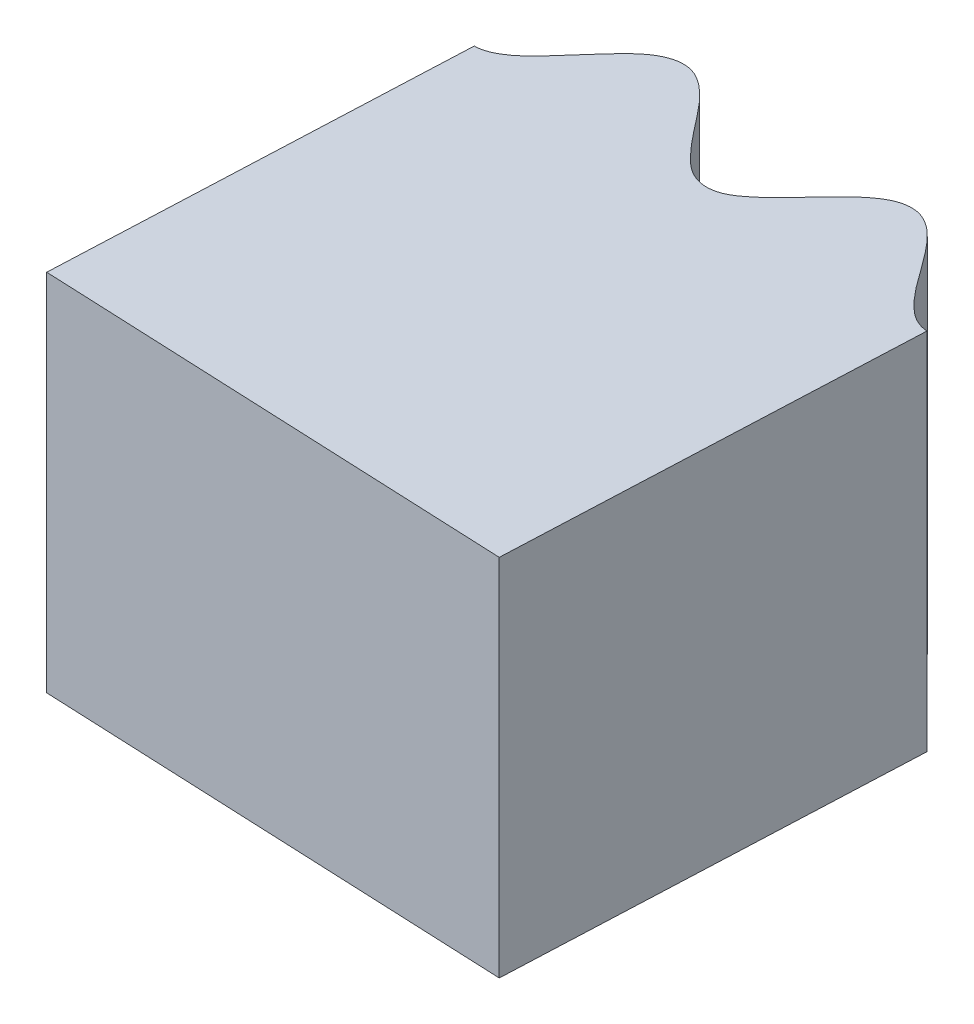
from build123d import *

# Parameters (mm, degrees)
BOSS_EXTRUDE1_DEPTH     = 4
CUT_EXTRUDE1_DEPTH      = 107.826952485
CUT_EXTRUDE1_DEPTH_BACK = 107.826952485
CUT_EXTRUDE2_DEPTH      = 107.826952485
CUT_EXTRUDE2_DEPTH_BACK = 107.826952485
BOSS_EXTRUDE2_DEPTH     = 4


with BuildPart() as part:
    # Sketch1 → Boss-Extrude1 (new body)
    with BuildSketch(Plane(origin=(0, 0, 0), x_dir=(1, 0, 0), z_dir=(0, 1, 0))):
        with BuildLine():
            Line((0, 75), (0, 70))
            ThreePointArc((0, 70), (49.497474683, 49.497474683), (70, 0))
            Line((70, 0), (75, 0))
            add(Edge.make_bspline(
                [(75, 0), (75.031777855, 0.026481546), (75.095718036, 0.079819595), (75.241427751, 0.203111666), (75.354120049, 0.325005398), (75.49263484, 0.505895966), (75.521616194, 0.741052344), (75.387194033, 0.961837859), (75.204794388, 1.132550458), (75.012763118, 1.292322408), (74.827909129, 1.434094195), (74.659688399, 1.589431482), (74.516508731, 1.747740796), (74.435301549, 1.990442591), (74.557176398, 2.236119215), (74.743732486, 2.433020792), (74.971286904, 2.627170766), (75.184213901, 2.831860151), (75.396738703, 3.044470229), (75.480370233, 3.37207249), (75.263556366, 3.636944802), (75.040650584, 3.822472036), (74.777383796, 4.010107495), (74.562819356, 4.184559741), (74.374958391, 4.384835516), (74.336857576, 4.635729115), (74.442274354, 4.835162175), (74.587135112, 5.0087381), (74.759757076, 5.179617259), (74.951973417, 5.354990353), (75.129486645, 5.551339985), (75.290054051, 5.777106095), (75.271282724, 6.055358963), (75.09620029, 6.247386328), (74.916555915, 6.398761228), (74.722111148, 6.530990099), (74.543350518, 6.654439025), (74.373583197, 6.786650419), (74.232516382, 6.923964863), (74.117997639, 7.140987023), (74.196142559, 7.40620448), (74.378877991, 7.621272004), (74.5932695, 7.846450763), (74.790579804, 8.043756236), (74.942235911, 8.240257531), (75.031626892, 8.443006893), (75.013933032, 8.637322476), (74.887419593, 8.818119346), (74.697982548, 8.975126902), (74.466865412, 9.123338974), (74.20856507, 9.289237483), (73.989820953, 9.451847774), (73.840027413, 9.667045575), (73.863757101, 9.895288267), (73.953590648, 10.058794794), (74.07609209, 10.222725068), (74.222147367, 10.387467054), (74.387036369, 10.561793098), (74.545599639, 10.760070197), (74.679775488, 10.9703129), (74.690515378, 11.221092601), (74.549634297, 11.408193312), (74.38809788, 11.539271657), (74.16550239, 11.683318077), (73.936586266, 11.812168652), (73.714963784, 11.954511577), (73.517288694, 12.139168151), (73.441094189, 12.359959327), (73.522095707, 12.580242239), (73.645005322, 12.764599436), (73.789630676, 12.941231814), (73.935098708, 13.109956075), (74.07848904, 13.287933998), (74.198419381, 13.473845208), (74.277410601, 13.707052688), (74.179200659, 13.944365708), (73.984265056, 14.097558217), (73.773817376, 14.231040782), (73.564520841, 14.340626908), (73.373575895, 14.447954179), (73.203525778, 14.562983122), (73.062426387, 14.689045185), (72.964311873, 14.898094952), (73.03521508, 15.149689821), (73.187174005, 15.373007802), (73.374719276, 15.611401558), (73.54101317, 15.820587549), (73.666083057, 16.021895989), (73.731374958, 16.217051043), (73.713914908, 16.39368128), (73.590497424, 16.570393243), (73.385208789, 16.714186298), (73.1668676, 16.827983407), (72.946766548, 16.93585278), (72.767754543, 17.03375874), (72.631281692, 17.124483788), (72.49758224, 17.242341241), (72.407119177, 17.423545501), (72.446790026, 17.638061133), (72.550050598, 17.829570173), (72.677037293, 18.016867634), (72.811599962, 18.196517221), (72.94890752, 18.387627652), (73.063188286, 18.586138857), (73.144605423, 18.830963502), (73.036496161, 19.080658625), (72.815265215, 19.226832107), (72.584482807, 19.351740928), (72.358507194, 19.448369637), (72.16218642, 19.544292981), (71.991493102, 19.64606248), (71.857216036, 19.756965783), (71.747380664, 19.953004782), (71.801427219, 20.215724769), (71.948636358, 20.460050217), (72.135214019, 20.731193805), (72.293878791, 20.968686197), (72.401411299, 21.196546331), (72.417671473, 21.411477454), (72.341127257, 21.571803105), (72.187166387, 21.70735538), (71.97956988, 21.821565415), (71.732256919, 21.922897166), (71.45348744, 22.041410101), (71.212156305, 22.163917654), (71.032972046, 22.355274835), (71.026028998, 22.586216973), (71.090181713, 22.763403023), (71.184661229, 22.946233885), (71.299948815, 23.132087687), (71.429688897, 23.329996364), (71.548183625, 23.548604147), (71.640166853, 23.775996811), (71.606198449, 24.021543722), (71.435944528, 24.180163494), (71.254606694, 24.281564876), (71.058065114, 24.363490545), (70.862292733, 24.437318197), (70.664024895, 24.511875688), (70.475013099, 24.602736191), (70.292140578, 24.720736257), (70.179268482, 24.925191886), (70.220467458, 25.156035578), (70.309698394, 25.35903485), (70.421337641, 25.558039839), (70.535359938, 25.749492169), (70.645634257, 25.949649828), (70.731474343, 26.153569682), (70.768762942, 26.396947677), (70.630839584, 26.613603146), (70.412261557, 26.73061695), (70.181833636, 26.825528545), (69.956686403, 26.89710538), (69.750005654, 26.969645113), (69.562564194, 27.053397507), (69.401718056, 27.153042793), (69.268792972, 27.341879198), (69.294930035, 27.601964001), (69.405801583, 27.848276662), (69.549100992, 28.115615582), (69.676543734, 28.350500195), (69.764756688, 28.570468467), (69.795168338, 28.773996496), (69.747302027, 28.944911417), (69.595073821, 29.097507508), (69.36793458, 29.203468026), (69.133149824, 29.277621751), (68.897661281, 29.3456322), (68.704367679, 29.410965639), (68.554213918, 29.476614108), (68.402079929, 29.569464375), (68.281525414, 29.732206989), (68.283343325, 29.950352418), (68.351779941, 30.156883015), (68.44431356, 30.363386015), (68.545636096, 30.563672884), (68.647671666, 30.775723125), (68.725745141, 30.991063145), (68.763412015, 31.246306292), (68.613586073, 31.473435008), (68.370333364, 31.578971436), (68.12136687, 31.661907667), (67.882044935, 31.717828115), (67.672049801, 31.778203423), (67.48627761, 31.848786231), (67.334782357, 31.934687696), (67.192573816, 32.10867571), (67.200178436, 32.376789476), (67.302724469, 32.64296567), (67.439384006, 32.942388848), (67.554398182, 33.203825046), (67.620729533, 33.446896297), (67.599420281, 33.661385683), (67.496198686, 33.805983863), (67.321038422, 33.91274177), (67.096763408, 33.989167943), (66.835611612, 34.046014791), (66.540497713, 34.114319436), (66.281559727, 34.193059113), (66.071868854, 34.350394128), (66.024928605, 34.576622089), (66.057338661, 34.762256286), (66.118634576, 34.958715732), (66.19989751, 35.161765477), (66.293300068, 35.379196605), (66.372033751, 35.615059639), (66.423133226, 35.854970417), (66.347042105, 36.090888367), (66.151830688, 36.217534065), (65.955639618, 36.285905948), (65.747857704, 36.332457895), (65.542239507, 36.371168422), (65.334037031, 36.410164368), (65.132118988, 36.466822942), (64.931534216, 36.551274842), (64.784873553, 36.733024296), (64.785361037, 36.967515081), (64.837985902, 37.182925127), (64.913372244, 37.398292735), (64.992416937, 37.606636238), (65.066258929, 37.822901988), (65.1153846, 38.038629816), (65.109844556, 38.284785449), (64.936394737, 38.474199294), (64.700818167, 38.55147972), (64.457409738, 38.604936006), (64.223253811, 38.636329021), (64.007116615, 38.671876977), (63.807979361, 38.721808116), (63.632273615, 38.792008928), (63.468576864, 38.954894285), (63.449153594, 39.215566469), (63.51556901, 39.477389729), (63.610268462, 39.765550851), (63.694987778, 40.018997239), (63.743663489, 40.250941718), (63.738270846, 40.456658626), (63.661452668, 40.616665068), (63.485039117, 40.740508731), (63.242950781, 40.805417155), (62.998856273, 40.837674373), (62.75513544, 40.863759434), (62.553433369, 40.89453523), (62.394161045, 40.933112424), (62.228215033, 40.998134297), (62.081232054, 41.137470414), (62.04514179, 41.3526174), (62.076675038, 41.567894227), (62.131943994, 41.787328277), (62.196947764, 42.002166811), (62.260611046, 42.228713824), (62.300105008, 42.454339662), (62.29287713, 42.712245876), (62.105886893, 42.909906995), (61.84800353, 42.971599697), (61.588417672, 43.010043363), (61.343021091, 43.023556436), (61.125732192, 43.046549235), (60.930525722, 43.083800729), (60.76641539, 43.142090283), (60.596154615, 43.288740774), (60.557086237, 43.554101818), (60.611853354, 43.834041129), (60.694442436, 44.152646076), (60.762311369, 44.430082472), (60.785426118, 44.680979243), (60.72719491, 44.88850974), (60.600432273, 45.012986908), (60.409394771, 45.087706661), (60.175255732, 45.124026802), (59.908200068, 45.134661485), (59.605708635, 45.150682439), (59.337031497, 45.183261773), (59.103205361, 45.301794078), (59.017694167, 45.516434039), (59.017376801, 45.704875983), (59.043626668, 45.908994692), (59.088395818, 46.123070815), (59.142622862, 46.35341786), (59.179203217, 46.599369565), (59.187866307, 46.84450889), (59.071964459, 47.063629632), (58.857726948, 47.15445319), (58.652643808, 47.187718129), (58.439934907, 47.197481897), (58.2307185, 47.199899099), (58.018907513, 47.202148628), (57.8102184, 47.222883731), (57.598016043, 47.271221436), (57.422023024, 47.424742351), (57.381784204, 47.655755345), (57.396204017, 47.87703104), (57.433046878, 48.102217432), (57.474712236, 48.321121695), (57.509878249, 48.54692441), (57.520796846, 48.76790543), (57.472596491, 49.009359388), (57.268890395, 49.165776366), (57.023473157, 49.200975287), (56.774480063, 49.211352021), (56.53843015, 49.201607356), (56.319403726, 49.199083429), (56.114621364, 49.21367618), (55.929394739, 49.252299501), (55.739900165, 49.384284621), (55.675506728, 49.637623793), (55.695448012, 49.907002286), (55.738670113, 50.20722998), (55.778091849, 50.471537303), (55.785751331, 50.708410473), (55.744718248, 50.910065656), (55.641282283, 51.054301904), (55.446043625, 51.145630211), (55.196361924, 51.167514333), (54.950374353, 51.156894925), (54.705826565, 51.140262017), (54.50184464, 51.135545062), (54.338293161, 51.145878833), (54.163577312, 51.181096655), (53.994631872, 51.292792616), (53.921730018, 51.498404028), (53.915401777, 51.715886007), (53.93172675, 51.941583714), (53.958436647, 52.164446155), (53.981793265, 52.398606422), (53.981507709, 52.627662551), (53.929604695, 52.880395482), (53.711131766, 53.042583171), (53.446453406, 53.058557646), (53.184135568, 53.051340655), (52.940120591, 53.022035765), (52.722140142, 53.006947431), (52.523430643, 53.009735743), (52.351691641, 53.038642287), (52.158551919, 53.153499355), (52.073997615, 53.408044815), (52.079321747, 53.693241432), (52.105330943, 54.021347492), (52.123992476, 54.306354331), (52.103188284, 54.557453238), (52.009804459, 54.751719156), (51.863352375, 54.8522931), (51.662242263, 54.892704454), (51.425353283, 54.88781482), (51.160508319, 54.851914543), (50.859830046, 54.815164474), (50.589577898, 54.800594357), (50.338720462, 54.8767213), (50.217237659, 55.073253246), (50.184200123, 55.258773572), (50.174612637, 55.464359096), (50.181513408, 55.682935158), (50.194944606, 55.919240873), (50.188214241, 56.167738015), (50.154244909, 56.410760048), (50.001954501, 56.606273845), (49.775379289, 56.658788811), (49.567237762, 56.65532883), (49.304214116, 56.622616528), (49.045974591, 56.574162013), (48.784735515, 56.540755014), (48.514599645, 56.555143493), (48.314315917, 56.675304239), (48.234767361, 56.896116363), (48.210421731, 57.116347677), (48.207672526, 57.34461889), (48.210654473, 57.567374449), (48.206095412, 57.795882862), (48.178466158, 58.015388898), (48.089073978, 58.244810754), (47.861298976, 58.36347494), (47.613499364, 58.355525037), (47.366486168, 58.322505405), (47.135715107, 58.271920131), (46.920454152, 58.231400348), (46.716249037, 58.210211896), (46.527129475, 58.216083467), (46.317594842, 58.313159147), (46.210187699, 58.551465658), (46.183049138, 58.820218778), (46.173480266, 59.123382827), (46.166407152, 59.390533034), (46.132816888, 59.625118902), (46.057391347, 59.816614072), (45.93047829, 59.940646153), (45.72235154, 59.9967984), (45.513717654, 59.978327669), (45.311865022, 59.939560734), (45.113273529, 59.89213854), (44.954301098, 59.855003521), (44.794243364, 59.822776571), (44.631382698, 59.804613975), (44.453209133, 59.808947404), (44.267427743, 59.889602511), (44.159942282, 60.079454869), (44.115921547, 60.292484986), (44.092850071, 60.517684125), (44.080373146, 60.741617867), (44.062856518, 60.976596314), (44.022569133, 61.201606077), (43.927913894, 61.442260872), (43.684055477, 61.562835852), (43.353958764, 61.527452614), (43.057655888, 61.451833522), (42.781724885, 61.365093522), (42.520765044, 61.325729742), (42.346145279, 61.323321887), (42.136228611, 61.403418614), (42.00859642, 61.639053519), (41.96443396, 61.921106482), (41.932994948, 62.248569553), (41.901929178, 62.532592562), (41.837814595, 62.776211289), (41.712125374, 62.951331919), (41.550429164, 63.024936528), (41.345359591, 63.029817319), (41.112916943, 62.98386301), (40.858330593, 62.902520532), (40.568601415, 62.814115523), (40.304985094, 62.752837967), (40.044719777, 62.784248234), (39.890954446, 62.956697487), (39.826205222, 63.133666318), (39.781059352, 63.334453222), (39.749910227, 63.550930885), (39.72208366, 63.785933067), (39.672337508, 64.029563276), (39.596635565, 64.262881847), (39.412779744, 64.429147223), (39.180398851, 64.441219907), (38.976306458, 64.402336159), (38.773086069, 64.338760371), (38.575660223, 64.269475572), (38.375853617, 64.199145814), (38.172658175, 64.147254557), (37.956720717, 64.120099661), (37.73883413, 64.204168975), (37.622010911, 64.407487694), (37.559880357, 64.620350698), (37.517483041, 64.844557689), (37.481766002, 65.064510802), (37.437582168, 65.288723431), (37.372262333, 65.500112046), (37.244386698, 65.710519055), (36.999467825, 65.787831348), (36.756812318, 65.736969875), (36.519286292, 65.661560162), (36.300804803, 65.571669347), (36.095850523, 65.494386182), (35.898427033, 65.43805919), (35.711160987, 65.411002003), (35.487952764, 65.470216484), (35.340795627, 65.686253583), (35.267401434, 65.946206885), (35.205333004, 66.243111463), (35.15197889, 66.504962132), (35.078161053, 66.730169799), (34.970632433, 66.905629546), (34.824102718, 67.0057901), (34.609402271, 67.024835082), (34.367293409, 66.960003259), (34.139772755, 66.865891575), (33.915661792, 66.766621484), (33.725594777, 66.69242307), (33.568372301, 66.646195738), (33.392147902, 66.619533326), (33.19518885, 66.666710453), (33.056360272, 66.834988077), (32.976030452, 67.037189902), (32.914177747, 67.254859841), (32.863053396, 67.473417355), (32.804913909, 67.701444464), (32.726303764, 67.916589152), (32.591091132, 68.136328546), (32.330322276, 68.214012978), (32.076142382, 68.138498744), (31.832112601, 68.041999006), (31.612836391, 67.93100338), (31.413162286, 67.842271279), (31.225482777, 67.776928784), (31.054214284, 67.745353852), (30.833438881, 67.787226516), (30.666924151, 67.997501732), (30.57438421, 68.267319845), (30.48660598, 68.584534364), (30.406664002, 68.858735798), (30.301233577, 69.08757615), (30.147038623, 69.238187228), (29.975020375, 69.282606299), (29.772217168, 69.251796753), (29.551286743, 69.166181397), (29.314692411, 69.041863471), (29.044716669, 68.904492308), (28.795745775, 68.79836827), (28.533980248, 68.784107189), (28.352605402, 68.927235251), (28.258109583, 69.090272079), (28.17878328, 69.280169), (28.110516439, 69.487948936), (28.042304915, 69.71454885), (27.951008579, 69.945839452), (27.835941372, 70.16246788), (27.626007056, 70.294281085), (27.39506015, 70.265817838), (27.200820472, 70.192084551), (27.011727277, 70.094185771), (26.829331953, 69.991670926), (26.644773492, 69.887713582), (26.453675867, 69.801326151), (26.245734383, 69.737086653), (26.0165595, 69.782043156), (25.866205162, 69.961986868), (25.768055239, 70.160827147), (25.687368897, 70.374265714), (25.614000025, 70.584675045), (25.531553326, 70.797808939), (25.430518602, 70.994643414), (25.268048884, 71.1796485), (25.013425752, 71.213256525), (24.783288709, 71.121031072), (24.56246604, 71.005521027), (24.362913066, 70.87905697), (24.174492743, 70.767357922), (23.989849337, 70.67760453), (23.810127224, 70.618439833), (23.580026692, 70.637995285), (23.397592404, 70.825196202), (23.280169338, 71.068456565), (23.167493339, 71.350070393), (23.06946958, 71.59868139), (22.957681398, 71.807644526), (22.821294864, 71.961773868), (22.659639521, 72.034955155), (22.444805134, 72.016456555), (22.217851484, 71.910498408), (21.975268013, 71.756572281), (21.739375045, 71.59560248), (21.524536447, 71.475767579), (21.31636641, 71.405962904), (21.114402091, 71.418142198), (20.948337894, 71.559827874), (20.834195973, 71.744924948), (20.735438656, 71.948671196), (20.6471559, 72.154821625), (20.550310914, 72.369644206), (20.435503805, 72.567302127), (20.264244385, 72.761071001), (19.993855404, 72.79096921), (19.695766223, 72.64482065), (19.443197121, 72.472419948), (19.213572824, 72.296537329), (18.981814359, 72.170293825), (18.818548855, 72.108307752), (18.593897085, 72.111778302), (18.393370125, 72.289549919), (18.255403228, 72.539488545), (18.113861231, 72.836450409), (17.98752738, 73.09271961), (17.84395686, 73.299717854), (17.665952846, 73.421289172), (17.488833851, 73.435151519), (17.294462158, 73.369600037), (17.091754817, 73.246917044), (16.880342668, 73.083406459), (16.638322591, 72.901239708), (16.411562438, 72.75349555), (16.156250096, 72.693995565), (15.952776831, 72.803454015), (15.831405558, 72.94760478), (15.720309152, 73.120841955), (15.616998826, 73.313610792), (15.51047493, 73.524923357), (15.380402395, 73.736846687), (15.229466191, 73.930202828), (14.999832118, 74.023558795), (14.77733642, 73.955424434), (14.598851297, 73.849082017), (14.429630869, 73.71983471), (14.26780791, 73.587204965), (14.104105589, 73.45277818), (13.930911694, 73.334520381), (13.737285198, 73.235146561), (13.503783958, 73.239627061), (13.324469783, 73.390722707), (13.193276262, 73.569511255), (13.076766208, 73.765669361), (12.967948079, 73.960193939), (12.849792798, 74.155677171), (12.716030197, 74.332137505), (12.525319389, 74.484839487), (12.272376417, 74.475738944), (12.064383281, 74.349458595), (11.871333179, 74.201935258), (11.69902874, 74.04587556), (11.535311347, 73.903768679), (11.369349318, 73.780742289), (11.203823948, 73.686964931), (10.97354784, 73.653912641), (10.75684998, 73.797450806), (10.596618108, 74.013302109), (10.441848096, 74.265394678), (10.284212826, 74.515639726), (10.113219322, 74.748113132), (9.873286325, 74.896632083), (9.633949193, 74.833571679), (9.474380411, 74.730713343), (9.341392659, 74.627643358), (9.191645745, 74.489765188), (9.041514121, 74.347579016), (8.890224761, 74.208744539), (8.720905845, 74.089154518), (8.567849769, 74.016211975), (8.392932977, 74.009242029), (8.237261246, 74.090266397), (8.093469699, 74.229722922), (7.953396319, 74.413698858), (7.813584442, 74.63370196), (7.645206709, 74.87187532), (7.472519084, 75.07780768), (7.233978127, 75.187930342), (7.009050477, 75.119477307), (6.849055481, 75.010097156), (6.691018449, 74.870284115), (6.538759179, 74.718133928), (6.37819219, 74.551014984), (6.200438479, 74.39754685), (5.994292605, 74.256063352), (5.729266048, 74.258761545), (5.531847891, 74.430643479), (5.374435541, 74.615297998), (5.235350827, 74.813620475), (5.104368315, 74.99452911), (4.9671184, 75.160990379), (4.819712758, 75.298933323), (4.634665994, 75.381103925), (4.445863352, 75.34697455), (4.296898598, 75.256631179), (4.170518027, 75.151912585), (4.054691013, 75.036512122), (3.943151072, 74.916746427), (3.832525792, 74.797629011), (3.71924554, 74.67575842), (3.575076676, 74.554329637), (3.386717156, 74.408746154), (3.098129201, 74.416795522), (2.872838807, 74.637964997), (2.6872824, 74.857553565), (2.497260034, 75.114685047), (2.308944685, 75.331277495), (2.034265399, 75.532136682), (1.713029895, 75.425690719), (1.506918744, 75.210033295), (1.304634645, 74.988931016), (1.113184466, 74.757632834), (0.910180099, 74.564825426), (0.64761275, 74.446879266), (0.390293126, 74.578169508), (0.246810519, 74.710506476), (0.094446915, 74.886712331), (0.031799211, 74.961840947), (0, 75)],
                knots=[0.078414566, 0.078414566, 0.078414566, 0.078414566, 0.078414566, 0.079498448, 0.080582329, 0.08166621, 0.082750092, 0.084162539, 0.085574986, 0.086987433, 0.08839988, 0.089592127, 0.090784373, 0.091976619, 0.093168865, 0.09480144, 0.096434016, 0.098066591, 0.099699166, 0.101370935, 0.103042704, 0.104756589, 0.106470474, 0.108184358, 0.109898243, 0.111083096, 0.112267949, 0.113452802, 0.114637655, 0.116134785, 0.117631916, 0.119129047, 0.120626177, 0.121954609, 0.12328304, 0.124611472, 0.125939903, 0.127051, 0.128162096, 0.129273193, 0.13038429, 0.132098122, 0.133811954, 0.135525787, 0.137239619, 0.13826081, 0.139282001, 0.140303192, 0.141324384, 0.143010002, 0.14469562, 0.146381239, 0.148066857, 0.149094912, 0.150122968, 0.151151023, 0.152179078, 0.15359219, 0.155005301, 0.156418413, 0.157831524, 0.158994851, 0.160158178, 0.161321505, 0.162484831, 0.164811485, 0.165974812, 0.167138138, 0.168382529, 0.169626919, 0.17087131, 0.1721157, 0.173360091, 0.174604481, 0.175848872, 0.177093262, 0.178476974, 0.179860685, 0.181244397, 0.182628108, 0.183671154, 0.1847142, 0.185757246, 0.186800292, 0.188463725, 0.190127158, 0.19179059, 0.193454023, 0.194391964, 0.195329906, 0.196267847, 0.197205788, 0.199009275, 0.200812761, 0.201714504, 0.202616247, 0.20351799, 0.204419733, 0.205633729, 0.206847725, 0.208061721, 0.209275716, 0.21057303, 0.211870343, 0.213167656, 0.214464969, 0.215934003, 0.217403037, 0.218872071, 0.220341105, 0.221303105, 0.222265105, 0.223227105, 0.224189105, 0.225993038, 0.227796971, 0.229600904, 0.231404836, 0.232342781, 0.233280725, 0.234218669, 0.235156613, 0.236819491, 0.238482368, 0.240145245, 0.241808123, 0.242851709, 0.243895295, 0.244938881, 0.245982467, 0.247366041, 0.248749616, 0.25013319, 0.251516765, 0.252680092, 0.253843418, 0.255006745, 0.256170072, 0.257333399, 0.258496725, 0.259660052, 0.260823379, 0.262067769, 0.26331216, 0.26455655, 0.265800941, 0.267045331, 0.268289722, 0.269534112, 0.270778503, 0.272162214, 0.273545926, 0.274929637, 0.276313349, 0.277356395, 0.278399441, 0.279442487, 0.280485533, 0.282148965, 0.283812398, 0.285475831, 0.287139263, 0.288077205, 0.289015146, 0.289953088, 0.290891029, 0.292694515, 0.294498001, 0.295399744, 0.296301487, 0.29720323, 0.298104973, 0.299318969, 0.300532965, 0.301746961, 0.302960957, 0.30425827, 0.305555583, 0.306852896, 0.308150209, 0.309619243, 0.311088277, 0.312557311, 0.314026345, 0.314988345, 0.315950345, 0.316912346, 0.317874346, 0.319678279, 0.321482211, 0.323286144, 0.325090077, 0.326028021, 0.326965965, 0.327903909, 0.328841854, 0.330504731, 0.332167608, 0.333830486, 0.335493363, 0.336536949, 0.337580535, 0.338624121, 0.339667707, 0.341051282, 0.342434856, 0.343818431, 0.345202005, 0.346365332, 0.347528659, 0.348691985, 0.349855312, 0.351018639, 0.352181966, 0.353345292, 0.354508619, 0.35575301, 0.3569974, 0.358241791, 0.359486181, 0.360730572, 0.361974962, 0.363219352, 0.364463743, 0.365847454, 0.367231166, 0.368614877, 0.369998589, 0.371041635, 0.372084681, 0.373127727, 0.374170773, 0.375834206, 0.377497638, 0.379161071, 0.380824504, 0.381762445, 0.382700387, 0.383638328, 0.384576269, 0.386379755, 0.388183241, 0.389084985, 0.389986728, 0.390888471, 0.391790214, 0.39300421, 0.394218205, 0.395432201, 0.396646197, 0.39794351, 0.399240823, 0.400538137, 0.40183545, 0.403304484, 0.404773517, 0.406242551, 0.407711585, 0.408673586, 0.409635586, 0.410597586, 0.411559586, 0.413363519, 0.415167452, 0.416971384, 0.418775317, 0.419713261, 0.420651206, 0.42158915, 0.422527094, 0.424189971, 0.425852849, 0.427515726, 0.429178604, 0.43022219, 0.431265776, 0.432309361, 0.433352947, 0.434736522, 0.436120097, 0.437503671, 0.438887246, 0.440050572, 0.441213899, 0.442377226, 0.443540553, 0.444703879, 0.445867206, 0.447030533, 0.44819386, 0.44943825, 0.45068264, 0.451927031, 0.453171421, 0.454415812, 0.455660202, 0.456904593, 0.458148983, 0.459532695, 0.460916406, 0.462300118, 0.463683829, 0.464726875, 0.465769921, 0.466812968, 0.467856014, 0.469519446, 0.471182879, 0.472846312, 0.474509744, 0.475447686, 0.476385627, 0.477323568, 0.47826151, 0.480064996, 0.481868482, 0.482770225, 0.483671968, 0.484573711, 0.485475454, 0.48668945, 0.487903446, 0.489117442, 0.490331438, 0.491628751, 0.492926064, 0.494223377, 0.49552069, 0.496989724, 0.498458758, 0.499927792, 0.501396826, 0.502358826, 0.503320826, 0.504282826, 0.505244827, 0.507048759, 0.508852692, 0.510656625, 0.512460558, 0.513398502, 0.514336446, 0.51527439, 0.516212335, 0.517875212, 0.519538089, 0.521200967, 0.522863844, 0.52390743, 0.524951016, 0.525994602, 0.527038188, 0.528421762, 0.529805337, 0.531188912, 0.532572486, 0.533735813, 0.53489914, 0.536062466, 0.537225793, 0.539552446, 0.540715773, 0.5418791, 0.54312349, 0.544367881, 0.545612271, 0.546856662, 0.548101052, 0.549345443, 0.550589833, 0.551834224, 0.553217935, 0.554601647, 0.555985358, 0.55736907, 0.558412116, 0.559455162, 0.560498208, 0.561541254, 0.563204687, 0.564868119, 0.566531552, 0.568194985, 0.569132926, 0.570070867, 0.571008809, 0.57194675, 0.573750236, 0.574651979, 0.575553722, 0.576455465, 0.577357208, 0.578258951, 0.579160695, 0.58037469, 0.581588686, 0.582802682, 0.584016678, 0.585313991, 0.586611304, 0.587908617, 0.58920593, 0.590674964, 0.592143998, 0.595082066, 0.596044066, 0.597006067, 0.597968067, 0.598930067, 0.600734, 0.602537932, 0.604341865, 0.606145798, 0.607083742, 0.608021686, 0.608959631, 0.609897575, 0.611560452, 0.61322333, 0.614886207, 0.616549084, 0.61759267, 0.618636256, 0.619679842, 0.620723428, 0.622107003, 0.623490577, 0.624874152, 0.626257726, 0.627421053, 0.62858438, 0.629747707, 0.630911033, 0.63207436, 0.633237687, 0.634401014, 0.63556434, 0.636808731, 0.638053121, 0.639297512, 0.640541902, 0.641786293, 0.643030683, 0.644275074, 0.645519464, 0.646903176, 0.648286887, 0.649670599, 0.65105431, 0.652097356, 0.653140402, 0.654183448, 0.655226494, 0.656889927, 0.65855336, 0.660216792, 0.661880225, 0.662818166, 0.663756108, 0.664694049, 0.66563199, 0.667435477, 0.669238963, 0.670140706, 0.671042449, 0.671944192, 0.672845935, 0.674059931, 0.675273927, 0.676487923, 0.677701918, 0.678999232, 0.680296545, 0.681593858, 0.682891171, 0.684360205, 0.685829239, 0.687298273, 0.688767307, 0.689729307, 0.690691307, 0.691653307, 0.692615307, 0.69441924, 0.696223173, 0.698027106, 0.699831038, 0.700768983, 0.701706927, 0.702644871, 0.703582815, 0.705245693, 0.70690857, 0.708571447, 0.710234325, 0.711277911, 0.712321497, 0.713365083, 0.714408669, 0.715792243, 0.717175818, 0.718559392, 0.719942967, 0.721106294, 0.72226962, 0.723432947, 0.724596274, 0.725759601, 0.726922927, 0.728086254, 0.729249581, 0.730493971, 0.731738362, 0.732982752, 0.734227143, 0.735471533, 0.736715924, 0.737960314, 0.739204705, 0.740588416, 0.741972128, 0.743355839, 0.744739551, 0.745782597, 0.746825643, 0.747868689, 0.748911735, 0.750575167, 0.7522386, 0.753902033, 0.755565465, 0.756503407, 0.757441348, 0.75837929, 0.759317231, 0.761120717, 0.762924203, 0.764727689, 0.765629432, 0.766531175, 0.767745171, 0.768959167, 0.770173163, 0.771387159, 0.772684472, 0.773981785, 0.775279098, 0.776576411, 0.778045445, 0.779514479, 0.782452547, 0.783414547, 0.784376547, 0.785338548, 0.786300548, 0.788104481, 0.789908413, 0.791712346, 0.793516279, 0.794454223, 0.795392167, 0.796330111, 0.797268056, 0.798930933, 0.800593811, 0.802256688, 0.803919565, 0.804963151, 0.806006737, 0.807050323, 0.808093909, 0.809477484, 0.810861058, 0.812244633, 0.813628207, 0.814791534, 0.815954861, 0.817118187, 0.818281514, 0.819444841, 0.820608168, 0.821771494, 0.822934821, 0.824179212, 0.825423602, 0.826667993, 0.827912383, 0.829156774, 0.830401164, 0.831645554, 0.832889945, 0.834239403, 0.835588861, 0.83693832, 0.838287778, 0.83934557, 0.840403362, 0.841461155, 0.842518947, 0.844153052, 0.845787158, 0.847421263, 0.849055368, 0.850645771, 0.852236173, 0.853144554, 0.854052935, 0.854961316, 0.855869697, 0.857686459, 0.85859484, 0.859503221, 0.860438045, 0.861372869, 0.862307692, 0.863242516, 0.864852032, 0.866461547, 0.868071063, 0.869680578, 0.87076911, 0.871857642, 0.872946173, 0.874034705, 0.875354272, 0.87667384, 0.877993407, 0.879312975, 0.880691541, 0.882070106, 0.883448672, 0.884827237, 0.885943532, 0.887059827, 0.888176122, 0.889292417, 0.890195375, 0.891098332, 0.892001289, 0.892904246, 0.893807204, 0.894710161, 0.895613118, 0.896516075, 0.898104044, 0.899692013, 0.901379743, 0.903067472, 0.904755202, 0.906442932, 0.908114225, 0.909785517, 0.911433348, 0.913081178, 0.914729009, 0.916376839, 0.917678371, 0.918979903, 0.920281434, 0.921582966, 0.921582966, 0.921582966, 0.921582966, 0.921582966], degree=4))
        make_face()
    extrude(amount=BOSS_EXTRUDE1_DEPTH)

    # Sketch2 → Cut-Extrude1 (cut, two sides)
    with BuildSketch(Plane(origin=(0, 4, 0), x_dir=(1, 0, 0), z_dir=(0, 1, 0))) as cut_extrude1_sk:
        with BuildLine():
            Line((0.453726334, 69.998529502), (0.65012339, 74.496761628))
            add(Edge.make_bspline(
                [(0.65012339, 74.496761628), (0.615879918, 74.497220315), (0.522751139, 74.511429164), (0.375458807, 74.591851506), (0.246810519, 74.710506476), (0.094446915, 74.886712331), (0.031799211, 74.961840947), (0, 75)],
                knots=[0.916915088, 0.916915088, 0.916915088, 0.916915088, 0.916915088, 0.917678371, 0.918979903, 0.920281434, 0.921582966, 0.921582966, 0.921582966, 0.921582966, 0.921582966], degree=4))
            Line((0, 75), (0, 70))
            ThreePointArc((0, 70), (0.226864358, 69.999632374), (0.453726334, 69.998529502))
        make_face()
    extrude(amount=CUT_EXTRUDE1_DEPTH, mode=Mode.SUBTRACT)
    extrude(cut_extrude1_sk.sketch, amount=-CUT_EXTRUDE1_DEPTH_BACK, mode=Mode.SUBTRACT)

    # Sketch3 → Cut-Extrude2 (cut, two sides)
    with BuildSketch(Plane(origin=(0, 4, 0), x_dir=(1, 0, 0), z_dir=(0, 1, 0))) as cut_extrude2_sk:
        with BuildLine():
            Line((5.845282701, 74.271358734), (5.648823568, 69.771704811))
            ThreePointArc((5.648823568, 69.771704811), (51.455892033, 47.458309864), (70, 0))
            Line((70, 0), (75, 0))
            add(Edge.make_bspline(
                [(75, 0), (75.031777855, 0.026481546), (75.095718036, 0.079819595), (75.241427751, 0.203111666), (75.354120049, 0.325005398), (75.49263484, 0.505895966), (75.521616194, 0.741052344), (75.387194033, 0.961837859), (75.204794388, 1.132550458), (75.012763118, 1.292322408), (74.827909129, 1.434094195), (74.659688399, 1.589431482), (74.516508731, 1.747740796), (74.435301549, 1.990442591), (74.557176398, 2.236119215), (74.743732486, 2.433020792), (74.971286904, 2.627170766), (75.184213901, 2.831860151), (75.396738703, 3.044470229), (75.480370233, 3.37207249), (75.263556366, 3.636944802), (75.040650584, 3.822472036), (74.777383796, 4.010107495), (74.562819356, 4.184559741), (74.374958391, 4.384835516), (74.336857576, 4.635729115), (74.442274354, 4.835162175), (74.587135112, 5.0087381), (74.759757076, 5.179617259), (74.951973417, 5.354990353), (75.129486645, 5.551339985), (75.290054051, 5.777106095), (75.271282724, 6.055358963), (75.09620029, 6.247386328), (74.916555915, 6.398761228), (74.722111148, 6.530990099), (74.543350518, 6.654439025), (74.373583197, 6.786650419), (74.232516382, 6.923964863), (74.117997639, 7.140987023), (74.196142559, 7.40620448), (74.378877991, 7.621272004), (74.5932695, 7.846450763), (74.790579804, 8.043756236), (74.942235911, 8.240257531), (75.031626892, 8.443006893), (75.013933032, 8.637322476), (74.887419593, 8.818119346), (74.697982548, 8.975126902), (74.466865412, 9.123338974), (74.20856507, 9.289237483), (73.989820953, 9.451847774), (73.840027413, 9.667045575), (73.863757101, 9.895288267), (73.953590648, 10.058794794), (74.07609209, 10.222725068), (74.222147367, 10.387467054), (74.387036369, 10.561793098), (74.545599639, 10.760070197), (74.679775488, 10.9703129), (74.690515378, 11.221092601), (74.549634297, 11.408193312), (74.38809788, 11.539271657), (74.16550239, 11.683318077), (73.936586266, 11.812168652), (73.714963784, 11.954511577), (73.517288694, 12.139168151), (73.441094189, 12.359959327), (73.522095707, 12.580242239), (73.645005322, 12.764599436), (73.789630676, 12.941231814), (73.935098708, 13.109956075), (74.07848904, 13.287933998), (74.198419381, 13.473845208), (74.277410601, 13.707052688), (74.179200659, 13.944365708), (73.984265056, 14.097558217), (73.773817376, 14.231040782), (73.564520841, 14.340626908), (73.373575895, 14.447954179), (73.203525778, 14.562983122), (73.062426387, 14.689045185), (72.964311873, 14.898094952), (73.03521508, 15.149689821), (73.187174005, 15.373007802), (73.374719276, 15.611401558), (73.54101317, 15.820587549), (73.666083057, 16.021895989), (73.731374958, 16.217051043), (73.713914908, 16.39368128), (73.590497424, 16.570393243), (73.385208789, 16.714186298), (73.1668676, 16.827983407), (72.946766548, 16.93585278), (72.767754543, 17.03375874), (72.631281692, 17.124483788), (72.49758224, 17.242341241), (72.407119177, 17.423545501), (72.446790026, 17.638061133), (72.550050598, 17.829570173), (72.677037293, 18.016867634), (72.811599962, 18.196517221), (72.94890752, 18.387627652), (73.063188286, 18.586138857), (73.144605423, 18.830963502), (73.036496161, 19.080658625), (72.815265215, 19.226832107), (72.584482807, 19.351740928), (72.358507194, 19.448369637), (72.16218642, 19.544292981), (71.991493102, 19.64606248), (71.857216036, 19.756965783), (71.747380664, 19.953004782), (71.801427219, 20.215724769), (71.948636358, 20.460050217), (72.135214019, 20.731193805), (72.293878791, 20.968686197), (72.401411299, 21.196546331), (72.417671473, 21.411477454), (72.341127257, 21.571803105), (72.187166387, 21.70735538), (71.97956988, 21.821565415), (71.732256919, 21.922897166), (71.45348744, 22.041410101), (71.212156305, 22.163917654), (71.032972046, 22.355274835), (71.026028998, 22.586216973), (71.090181713, 22.763403023), (71.184661229, 22.946233885), (71.299948815, 23.132087687), (71.429688897, 23.329996364), (71.548183625, 23.548604147), (71.640166853, 23.775996811), (71.606198449, 24.021543722), (71.435944528, 24.180163494), (71.254606694, 24.281564876), (71.058065114, 24.363490545), (70.862292733, 24.437318197), (70.664024895, 24.511875688), (70.475013099, 24.602736191), (70.292140578, 24.720736257), (70.179268482, 24.925191886), (70.220467458, 25.156035578), (70.309698394, 25.35903485), (70.421337641, 25.558039839), (70.535359938, 25.749492169), (70.645634257, 25.949649828), (70.731474343, 26.153569682), (70.768762942, 26.396947677), (70.630839584, 26.613603146), (70.412261557, 26.73061695), (70.181833636, 26.825528545), (69.956686403, 26.89710538), (69.750005654, 26.969645113), (69.562564194, 27.053397507), (69.401718056, 27.153042793), (69.268792972, 27.341879198), (69.294930035, 27.601964001), (69.405801583, 27.848276662), (69.549100992, 28.115615582), (69.676543734, 28.350500195), (69.764756688, 28.570468467), (69.795168338, 28.773996496), (69.747302027, 28.944911417), (69.595073821, 29.097507508), (69.36793458, 29.203468026), (69.133149824, 29.277621751), (68.897661281, 29.3456322), (68.704367679, 29.410965639), (68.554213918, 29.476614108), (68.402079929, 29.569464375), (68.281525414, 29.732206989), (68.283343325, 29.950352418), (68.351779941, 30.156883015), (68.44431356, 30.363386015), (68.545636096, 30.563672884), (68.647671666, 30.775723125), (68.725745141, 30.991063145), (68.763412015, 31.246306292), (68.613586073, 31.473435008), (68.370333364, 31.578971436), (68.12136687, 31.661907667), (67.882044935, 31.717828115), (67.672049801, 31.778203423), (67.48627761, 31.848786231), (67.334782357, 31.934687696), (67.192573816, 32.10867571), (67.200178436, 32.376789476), (67.302724469, 32.64296567), (67.439384006, 32.942388848), (67.554398182, 33.203825046), (67.620729533, 33.446896297), (67.599420281, 33.661385683), (67.496198686, 33.805983863), (67.321038422, 33.91274177), (67.096763408, 33.989167943), (66.835611612, 34.046014791), (66.540497713, 34.114319436), (66.281559727, 34.193059113), (66.071868854, 34.350394128), (66.024928605, 34.576622089), (66.057338661, 34.762256286), (66.118634576, 34.958715732), (66.19989751, 35.161765477), (66.293300068, 35.379196605), (66.372033751, 35.615059639), (66.423133226, 35.854970417), (66.347042105, 36.090888367), (66.151830688, 36.217534065), (65.955639618, 36.285905948), (65.747857704, 36.332457895), (65.542239507, 36.371168422), (65.334037031, 36.410164368), (65.132118988, 36.466822942), (64.931534216, 36.551274842), (64.784873553, 36.733024296), (64.785361037, 36.967515081), (64.837985902, 37.182925127), (64.913372244, 37.398292735), (64.992416937, 37.606636238), (65.066258929, 37.822901988), (65.1153846, 38.038629816), (65.109844556, 38.284785449), (64.936394737, 38.474199294), (64.700818167, 38.55147972), (64.457409738, 38.604936006), (64.223253811, 38.636329021), (64.007116615, 38.671876977), (63.807979361, 38.721808116), (63.632273615, 38.792008928), (63.468576864, 38.954894285), (63.449153594, 39.215566469), (63.51556901, 39.477389729), (63.610268462, 39.765550851), (63.694987778, 40.018997239), (63.743663489, 40.250941718), (63.738270846, 40.456658626), (63.661452668, 40.616665068), (63.485039117, 40.740508731), (63.242950781, 40.805417155), (62.998856273, 40.837674373), (62.75513544, 40.863759434), (62.553433369, 40.89453523), (62.394161045, 40.933112424), (62.228215033, 40.998134297), (62.081232054, 41.137470414), (62.04514179, 41.3526174), (62.076675038, 41.567894227), (62.131943994, 41.787328277), (62.196947764, 42.002166811), (62.260611046, 42.228713824), (62.300105008, 42.454339662), (62.29287713, 42.712245876), (62.105886893, 42.909906995), (61.84800353, 42.971599697), (61.588417672, 43.010043363), (61.343021091, 43.023556436), (61.125732192, 43.046549235), (60.930525722, 43.083800729), (60.76641539, 43.142090283), (60.596154615, 43.288740774), (60.557086237, 43.554101818), (60.611853354, 43.834041129), (60.694442436, 44.152646076), (60.762311369, 44.430082472), (60.785426118, 44.680979243), (60.72719491, 44.88850974), (60.600432273, 45.012986908), (60.409394771, 45.087706661), (60.175255732, 45.124026802), (59.908200068, 45.134661485), (59.605708635, 45.150682439), (59.337031497, 45.183261773), (59.103205361, 45.301794078), (59.017694167, 45.516434039), (59.017376801, 45.704875983), (59.043626668, 45.908994692), (59.088395818, 46.123070815), (59.142622862, 46.35341786), (59.179203217, 46.599369565), (59.187866307, 46.84450889), (59.071964459, 47.063629632), (58.857726948, 47.15445319), (58.652643808, 47.187718129), (58.439934907, 47.197481897), (58.2307185, 47.199899099), (58.018907513, 47.202148628), (57.8102184, 47.222883731), (57.598016043, 47.271221436), (57.422023024, 47.424742351), (57.381784204, 47.655755345), (57.396204017, 47.87703104), (57.433046878, 48.102217432), (57.474712236, 48.321121695), (57.509878249, 48.54692441), (57.520796846, 48.76790543), (57.472596491, 49.009359388), (57.268890395, 49.165776366), (57.023473157, 49.200975287), (56.774480063, 49.211352021), (56.53843015, 49.201607356), (56.319403726, 49.199083429), (56.114621364, 49.21367618), (55.929394739, 49.252299501), (55.739900165, 49.384284621), (55.675506728, 49.637623793), (55.695448012, 49.907002286), (55.738670113, 50.20722998), (55.778091849, 50.471537303), (55.785751331, 50.708410473), (55.744718248, 50.910065656), (55.641282283, 51.054301904), (55.446043625, 51.145630211), (55.196361924, 51.167514333), (54.950374353, 51.156894925), (54.705826565, 51.140262017), (54.50184464, 51.135545062), (54.338293161, 51.145878833), (54.163577312, 51.181096655), (53.994631872, 51.292792616), (53.921730018, 51.498404028), (53.915401777, 51.715886007), (53.93172675, 51.941583714), (53.958436647, 52.164446155), (53.981793265, 52.398606422), (53.981507709, 52.627662551), (53.929604695, 52.880395482), (53.711131766, 53.042583171), (53.446453406, 53.058557646), (53.184135568, 53.051340655), (52.940120591, 53.022035765), (52.722140142, 53.006947431), (52.523430643, 53.009735743), (52.351691641, 53.038642287), (52.158551919, 53.153499355), (52.073997615, 53.408044815), (52.079321747, 53.693241432), (52.105330943, 54.021347492), (52.123992476, 54.306354331), (52.103188284, 54.557453238), (52.009804459, 54.751719156), (51.863352375, 54.8522931), (51.662242263, 54.892704454), (51.425353283, 54.88781482), (51.160508319, 54.851914543), (50.859830046, 54.815164474), (50.589577898, 54.800594357), (50.338720462, 54.8767213), (50.217237659, 55.073253246), (50.184200123, 55.258773572), (50.174612637, 55.464359096), (50.181513408, 55.682935158), (50.194944606, 55.919240873), (50.188214241, 56.167738015), (50.154244909, 56.410760048), (50.001954501, 56.606273845), (49.775379289, 56.658788811), (49.567237762, 56.65532883), (49.304214116, 56.622616528), (49.045974591, 56.574162013), (48.784735515, 56.540755014), (48.514599645, 56.555143493), (48.314315917, 56.675304239), (48.234767361, 56.896116363), (48.210421731, 57.116347677), (48.207672526, 57.34461889), (48.210654473, 57.567374449), (48.206095412, 57.795882862), (48.178466158, 58.015388898), (48.089073978, 58.244810754), (47.861298976, 58.36347494), (47.613499364, 58.355525037), (47.366486168, 58.322505405), (47.135715107, 58.271920131), (46.920454152, 58.231400348), (46.716249037, 58.210211896), (46.527129475, 58.216083467), (46.317594842, 58.313159147), (46.210187699, 58.551465658), (46.183049138, 58.820218778), (46.173480266, 59.123382827), (46.166407152, 59.390533034), (46.132816888, 59.625118902), (46.057391347, 59.816614072), (45.93047829, 59.940646153), (45.72235154, 59.9967984), (45.513717654, 59.978327669), (45.311865022, 59.939560734), (45.113273529, 59.89213854), (44.954301098, 59.855003521), (44.794243364, 59.822776571), (44.631382698, 59.804613975), (44.453209133, 59.808947404), (44.267427743, 59.889602511), (44.159942282, 60.079454869), (44.115921547, 60.292484986), (44.092850071, 60.517684125), (44.080373146, 60.741617867), (44.062856518, 60.976596314), (44.022569133, 61.201606077), (43.927913894, 61.442260872), (43.684055477, 61.562835852), (43.353958764, 61.527452614), (43.057655888, 61.451833522), (42.781724885, 61.365093522), (42.520765044, 61.325729742), (42.346145279, 61.323321887), (42.136228611, 61.403418614), (42.00859642, 61.639053519), (41.96443396, 61.921106482), (41.932994948, 62.248569553), (41.901929178, 62.532592562), (41.837814595, 62.776211289), (41.712125374, 62.951331919), (41.550429164, 63.024936528), (41.345359591, 63.029817319), (41.112916943, 62.98386301), (40.858330593, 62.902520532), (40.568601415, 62.814115523), (40.304985094, 62.752837967), (40.044719777, 62.784248234), (39.890954446, 62.956697487), (39.826205222, 63.133666318), (39.781059352, 63.334453222), (39.749910227, 63.550930885), (39.72208366, 63.785933067), (39.672337508, 64.029563276), (39.596635565, 64.262881847), (39.412779744, 64.429147223), (39.180398851, 64.441219907), (38.976306458, 64.402336159), (38.773086069, 64.338760371), (38.575660223, 64.269475572), (38.375853617, 64.199145814), (38.172658175, 64.147254557), (37.956720717, 64.120099661), (37.73883413, 64.204168975), (37.622010911, 64.407487694), (37.559880357, 64.620350698), (37.517483041, 64.844557689), (37.481766002, 65.064510802), (37.437582168, 65.288723431), (37.372262333, 65.500112046), (37.244386698, 65.710519055), (36.999467825, 65.787831348), (36.756812318, 65.736969875), (36.519286292, 65.661560162), (36.300804803, 65.571669347), (36.095850523, 65.494386182), (35.898427033, 65.43805919), (35.711160987, 65.411002003), (35.487952764, 65.470216484), (35.340795627, 65.686253583), (35.267401434, 65.946206885), (35.205333004, 66.243111463), (35.15197889, 66.504962132), (35.078161053, 66.730169799), (34.970632433, 66.905629546), (34.824102718, 67.0057901), (34.609402271, 67.024835082), (34.367293409, 66.960003259), (34.139772755, 66.865891575), (33.915661792, 66.766621484), (33.725594777, 66.69242307), (33.568372301, 66.646195738), (33.392147902, 66.619533326), (33.19518885, 66.666710453), (33.056360272, 66.834988077), (32.976030452, 67.037189902), (32.914177747, 67.254859841), (32.863053396, 67.473417355), (32.804913909, 67.701444464), (32.726303764, 67.916589152), (32.591091132, 68.136328546), (32.330322276, 68.214012978), (32.076142382, 68.138498744), (31.832112601, 68.041999006), (31.612836391, 67.93100338), (31.413162286, 67.842271279), (31.225482777, 67.776928784), (31.054214284, 67.745353852), (30.833438881, 67.787226516), (30.666924151, 67.997501732), (30.57438421, 68.267319845), (30.48660598, 68.584534364), (30.406664002, 68.858735798), (30.301233577, 69.08757615), (30.147038623, 69.238187228), (29.975020375, 69.282606299), (29.772217168, 69.251796753), (29.551286743, 69.166181397), (29.314692411, 69.041863471), (29.044716669, 68.904492308), (28.795745775, 68.79836827), (28.533980248, 68.784107189), (28.352605402, 68.927235251), (28.258109583, 69.090272079), (28.17878328, 69.280169), (28.110516439, 69.487948936), (28.042304915, 69.71454885), (27.951008579, 69.945839452), (27.835941372, 70.16246788), (27.626007056, 70.294281085), (27.39506015, 70.265817838), (27.200820472, 70.192084551), (27.011727277, 70.094185771), (26.829331953, 69.991670926), (26.644773492, 69.887713582), (26.453675867, 69.801326151), (26.245734383, 69.737086653), (26.0165595, 69.782043156), (25.866205162, 69.961986868), (25.768055239, 70.160827147), (25.687368897, 70.374265714), (25.614000025, 70.584675045), (25.531553326, 70.797808939), (25.430518602, 70.994643414), (25.268048884, 71.1796485), (25.013425752, 71.213256525), (24.783288709, 71.121031072), (24.56246604, 71.005521027), (24.362913066, 70.87905697), (24.174492743, 70.767357922), (23.989849337, 70.67760453), (23.810127224, 70.618439833), (23.580026692, 70.637995285), (23.397592404, 70.825196202), (23.280169338, 71.068456565), (23.167493339, 71.350070393), (23.06946958, 71.59868139), (22.957681398, 71.807644526), (22.821294864, 71.961773868), (22.659639521, 72.034955155), (22.444805134, 72.016456555), (22.217851484, 71.910498408), (21.975268013, 71.756572281), (21.739375045, 71.59560248), (21.524536447, 71.475767579), (21.31636641, 71.405962904), (21.114402091, 71.418142198), (20.948337894, 71.559827874), (20.834195973, 71.744924948), (20.735438656, 71.948671196), (20.6471559, 72.154821625), (20.550310914, 72.369644206), (20.435503805, 72.567302127), (20.264244385, 72.761071001), (19.993855404, 72.79096921), (19.695766223, 72.64482065), (19.443197121, 72.472419948), (19.213572824, 72.296537329), (18.981814359, 72.170293825), (18.818548855, 72.108307752), (18.593897085, 72.111778302), (18.393370125, 72.289549919), (18.255403228, 72.539488545), (18.113861231, 72.836450409), (17.98752738, 73.09271961), (17.84395686, 73.299717854), (17.665952846, 73.421289172), (17.488833851, 73.435151519), (17.294462158, 73.369600037), (17.091754817, 73.246917044), (16.880342668, 73.083406459), (16.638322591, 72.901239708), (16.411562438, 72.75349555), (16.156250096, 72.693995565), (15.952776831, 72.803454015), (15.831405558, 72.94760478), (15.720309152, 73.120841955), (15.616998826, 73.313610792), (15.51047493, 73.524923357), (15.380402395, 73.736846687), (15.229466191, 73.930202828), (14.999832118, 74.023558795), (14.77733642, 73.955424434), (14.598851297, 73.849082017), (14.429630869, 73.71983471), (14.26780791, 73.587204965), (14.104105589, 73.45277818), (13.930911694, 73.334520381), (13.737285198, 73.235146561), (13.503783958, 73.239627061), (13.324469783, 73.390722707), (13.193276262, 73.569511255), (13.076766208, 73.765669361), (12.967948079, 73.960193939), (12.849792798, 74.155677171), (12.716030197, 74.332137505), (12.525319389, 74.484839487), (12.272376417, 74.475738944), (12.064383281, 74.349458595), (11.871333179, 74.201935258), (11.69902874, 74.04587556), (11.535311347, 73.903768679), (11.369349318, 73.780742289), (11.203823948, 73.686964931), (10.97354784, 73.653912641), (10.75684998, 73.797450806), (10.596618108, 74.013302109), (10.441848096, 74.265394678), (10.284212826, 74.515639726), (10.113219322, 74.748113132), (9.873286325, 74.896632083), (9.633949193, 74.833571679), (9.474380411, 74.730713343), (9.341392659, 74.627643358), (9.191645745, 74.489765188), (9.041514121, 74.347579016), (8.890224761, 74.208744539), (8.720905845, 74.089154518), (8.567849769, 74.016211975), (8.392932977, 74.009242029), (8.237261246, 74.090266397), (8.093469699, 74.229722922), (7.953396319, 74.413698858), (7.813584442, 74.63370196), (7.645206709, 74.87187532), (7.472519084, 75.07780768), (7.233978127, 75.187930342), (7.009050477, 75.119477307), (6.849055481, 75.010097156), (6.691018449, 74.870284115), (6.538759179, 74.718133928), (6.37819219, 74.551014984), (6.200438479, 74.39754685), (6.042736056, 74.289311405), (5.916063038, 74.26739306), (5.850883928, 74.270941815), (5.845282701, 74.271358734)],
                knots=[0.078414566, 0.078414566, 0.078414566, 0.078414566, 0.078414566, 0.079498448, 0.080582329, 0.08166621, 0.082750092, 0.084162539, 0.085574986, 0.086987433, 0.08839988, 0.089592127, 0.090784373, 0.091976619, 0.093168865, 0.09480144, 0.096434016, 0.098066591, 0.099699166, 0.101370935, 0.103042704, 0.104756589, 0.106470474, 0.108184358, 0.109898243, 0.111083096, 0.112267949, 0.113452802, 0.114637655, 0.116134785, 0.117631916, 0.119129047, 0.120626177, 0.121954609, 0.12328304, 0.124611472, 0.125939903, 0.127051, 0.128162096, 0.129273193, 0.13038429, 0.132098122, 0.133811954, 0.135525787, 0.137239619, 0.13826081, 0.139282001, 0.140303192, 0.141324384, 0.143010002, 0.14469562, 0.146381239, 0.148066857, 0.149094912, 0.150122968, 0.151151023, 0.152179078, 0.15359219, 0.155005301, 0.156418413, 0.157831524, 0.158994851, 0.160158178, 0.161321505, 0.162484831, 0.164811485, 0.165974812, 0.167138138, 0.168382529, 0.169626919, 0.17087131, 0.1721157, 0.173360091, 0.174604481, 0.175848872, 0.177093262, 0.178476974, 0.179860685, 0.181244397, 0.182628108, 0.183671154, 0.1847142, 0.185757246, 0.186800292, 0.188463725, 0.190127158, 0.19179059, 0.193454023, 0.194391964, 0.195329906, 0.196267847, 0.197205788, 0.199009275, 0.200812761, 0.201714504, 0.202616247, 0.20351799, 0.204419733, 0.205633729, 0.206847725, 0.208061721, 0.209275716, 0.21057303, 0.211870343, 0.213167656, 0.214464969, 0.215934003, 0.217403037, 0.218872071, 0.220341105, 0.221303105, 0.222265105, 0.223227105, 0.224189105, 0.225993038, 0.227796971, 0.229600904, 0.231404836, 0.232342781, 0.233280725, 0.234218669, 0.235156613, 0.236819491, 0.238482368, 0.240145245, 0.241808123, 0.242851709, 0.243895295, 0.244938881, 0.245982467, 0.247366041, 0.248749616, 0.25013319, 0.251516765, 0.252680092, 0.253843418, 0.255006745, 0.256170072, 0.257333399, 0.258496725, 0.259660052, 0.260823379, 0.262067769, 0.26331216, 0.26455655, 0.265800941, 0.267045331, 0.268289722, 0.269534112, 0.270778503, 0.272162214, 0.273545926, 0.274929637, 0.276313349, 0.277356395, 0.278399441, 0.279442487, 0.280485533, 0.282148965, 0.283812398, 0.285475831, 0.287139263, 0.288077205, 0.289015146, 0.289953088, 0.290891029, 0.292694515, 0.294498001, 0.295399744, 0.296301487, 0.29720323, 0.298104973, 0.299318969, 0.300532965, 0.301746961, 0.302960957, 0.30425827, 0.305555583, 0.306852896, 0.308150209, 0.309619243, 0.311088277, 0.312557311, 0.314026345, 0.314988345, 0.315950345, 0.316912346, 0.317874346, 0.319678279, 0.321482211, 0.323286144, 0.325090077, 0.326028021, 0.326965965, 0.327903909, 0.328841854, 0.330504731, 0.332167608, 0.333830486, 0.335493363, 0.336536949, 0.337580535, 0.338624121, 0.339667707, 0.341051282, 0.342434856, 0.343818431, 0.345202005, 0.346365332, 0.347528659, 0.348691985, 0.349855312, 0.351018639, 0.352181966, 0.353345292, 0.354508619, 0.35575301, 0.3569974, 0.358241791, 0.359486181, 0.360730572, 0.361974962, 0.363219352, 0.364463743, 0.365847454, 0.367231166, 0.368614877, 0.369998589, 0.371041635, 0.372084681, 0.373127727, 0.374170773, 0.375834206, 0.377497638, 0.379161071, 0.380824504, 0.381762445, 0.382700387, 0.383638328, 0.384576269, 0.386379755, 0.388183241, 0.389084985, 0.389986728, 0.390888471, 0.391790214, 0.39300421, 0.394218205, 0.395432201, 0.396646197, 0.39794351, 0.399240823, 0.400538137, 0.40183545, 0.403304484, 0.404773517, 0.406242551, 0.407711585, 0.408673586, 0.409635586, 0.410597586, 0.411559586, 0.413363519, 0.415167452, 0.416971384, 0.418775317, 0.419713261, 0.420651206, 0.42158915, 0.422527094, 0.424189971, 0.425852849, 0.427515726, 0.429178604, 0.43022219, 0.431265776, 0.432309361, 0.433352947, 0.434736522, 0.436120097, 0.437503671, 0.438887246, 0.440050572, 0.441213899, 0.442377226, 0.443540553, 0.444703879, 0.445867206, 0.447030533, 0.44819386, 0.44943825, 0.45068264, 0.451927031, 0.453171421, 0.454415812, 0.455660202, 0.456904593, 0.458148983, 0.459532695, 0.460916406, 0.462300118, 0.463683829, 0.464726875, 0.465769921, 0.466812968, 0.467856014, 0.469519446, 0.471182879, 0.472846312, 0.474509744, 0.475447686, 0.476385627, 0.477323568, 0.47826151, 0.480064996, 0.481868482, 0.482770225, 0.483671968, 0.484573711, 0.485475454, 0.48668945, 0.487903446, 0.489117442, 0.490331438, 0.491628751, 0.492926064, 0.494223377, 0.49552069, 0.496989724, 0.498458758, 0.499927792, 0.501396826, 0.502358826, 0.503320826, 0.504282826, 0.505244827, 0.507048759, 0.508852692, 0.510656625, 0.512460558, 0.513398502, 0.514336446, 0.51527439, 0.516212335, 0.517875212, 0.519538089, 0.521200967, 0.522863844, 0.52390743, 0.524951016, 0.525994602, 0.527038188, 0.528421762, 0.529805337, 0.531188912, 0.532572486, 0.533735813, 0.53489914, 0.536062466, 0.537225793, 0.539552446, 0.540715773, 0.5418791, 0.54312349, 0.544367881, 0.545612271, 0.546856662, 0.548101052, 0.549345443, 0.550589833, 0.551834224, 0.553217935, 0.554601647, 0.555985358, 0.55736907, 0.558412116, 0.559455162, 0.560498208, 0.561541254, 0.563204687, 0.564868119, 0.566531552, 0.568194985, 0.569132926, 0.570070867, 0.571008809, 0.57194675, 0.573750236, 0.574651979, 0.575553722, 0.576455465, 0.577357208, 0.578258951, 0.579160695, 0.58037469, 0.581588686, 0.582802682, 0.584016678, 0.585313991, 0.586611304, 0.587908617, 0.58920593, 0.590674964, 0.592143998, 0.595082066, 0.596044066, 0.597006067, 0.597968067, 0.598930067, 0.600734, 0.602537932, 0.604341865, 0.606145798, 0.607083742, 0.608021686, 0.608959631, 0.609897575, 0.611560452, 0.61322333, 0.614886207, 0.616549084, 0.61759267, 0.618636256, 0.619679842, 0.620723428, 0.622107003, 0.623490577, 0.624874152, 0.626257726, 0.627421053, 0.62858438, 0.629747707, 0.630911033, 0.63207436, 0.633237687, 0.634401014, 0.63556434, 0.636808731, 0.638053121, 0.639297512, 0.640541902, 0.641786293, 0.643030683, 0.644275074, 0.645519464, 0.646903176, 0.648286887, 0.649670599, 0.65105431, 0.652097356, 0.653140402, 0.654183448, 0.655226494, 0.656889927, 0.65855336, 0.660216792, 0.661880225, 0.662818166, 0.663756108, 0.664694049, 0.66563199, 0.667435477, 0.669238963, 0.670140706, 0.671042449, 0.671944192, 0.672845935, 0.674059931, 0.675273927, 0.676487923, 0.677701918, 0.678999232, 0.680296545, 0.681593858, 0.682891171, 0.684360205, 0.685829239, 0.687298273, 0.688767307, 0.689729307, 0.690691307, 0.691653307, 0.692615307, 0.69441924, 0.696223173, 0.698027106, 0.699831038, 0.700768983, 0.701706927, 0.702644871, 0.703582815, 0.705245693, 0.70690857, 0.708571447, 0.710234325, 0.711277911, 0.712321497, 0.713365083, 0.714408669, 0.715792243, 0.717175818, 0.718559392, 0.719942967, 0.721106294, 0.72226962, 0.723432947, 0.724596274, 0.725759601, 0.726922927, 0.728086254, 0.729249581, 0.730493971, 0.731738362, 0.732982752, 0.734227143, 0.735471533, 0.736715924, 0.737960314, 0.739204705, 0.740588416, 0.741972128, 0.743355839, 0.744739551, 0.745782597, 0.746825643, 0.747868689, 0.748911735, 0.750575167, 0.7522386, 0.753902033, 0.755565465, 0.756503407, 0.757441348, 0.75837929, 0.759317231, 0.761120717, 0.762924203, 0.764727689, 0.765629432, 0.766531175, 0.767745171, 0.768959167, 0.770173163, 0.771387159, 0.772684472, 0.773981785, 0.775279098, 0.776576411, 0.778045445, 0.779514479, 0.782452547, 0.783414547, 0.784376547, 0.785338548, 0.786300548, 0.788104481, 0.789908413, 0.791712346, 0.793516279, 0.794454223, 0.795392167, 0.796330111, 0.797268056, 0.798930933, 0.800593811, 0.802256688, 0.803919565, 0.804963151, 0.806006737, 0.807050323, 0.808093909, 0.809477484, 0.810861058, 0.812244633, 0.813628207, 0.814791534, 0.815954861, 0.817118187, 0.818281514, 0.819444841, 0.820608168, 0.821771494, 0.822934821, 0.824179212, 0.825423602, 0.826667993, 0.827912383, 0.829156774, 0.830401164, 0.831645554, 0.832889945, 0.834239403, 0.835588861, 0.83693832, 0.838287778, 0.83934557, 0.840403362, 0.841461155, 0.842518947, 0.844153052, 0.845787158, 0.847421263, 0.849055368, 0.850645771, 0.852236173, 0.853144554, 0.854052935, 0.854961316, 0.855869697, 0.857686459, 0.85859484, 0.859503221, 0.860438045, 0.861372869, 0.862307692, 0.863242516, 0.864852032, 0.866461547, 0.868071063, 0.869680578, 0.87076911, 0.871857642, 0.872946173, 0.874034705, 0.875354272, 0.87667384, 0.877993407, 0.879312975, 0.879437304, 0.879437304, 0.879437304, 0.879437304, 0.879437304], degree=4))
        make_face()
    extrude(amount=CUT_EXTRUDE2_DEPTH, mode=Mode.SUBTRACT)
    extrude(cut_extrude2_sk.sketch, amount=-CUT_EXTRUDE2_DEPTH_BACK, mode=Mode.SUBTRACT)

    # Sketch4 → Boss-Extrude2 (add)
    with BuildSketch(Plane(origin=(0, 0, 0), x_dir=(1, 0, 0), z_dir=(0, 1, 0))):
        with BuildLine():
            Line((0.453726334, 69.998529502), (5.648823568, 69.771704811))
            ThreePointArc((5.648823568, 69.771704811), (3.053381926, 69.933374427), (0.453726334, 69.998529502))
        make_face()
    extrude(amount=BOSS_EXTRUDE2_DEPTH)


solid = part.part
